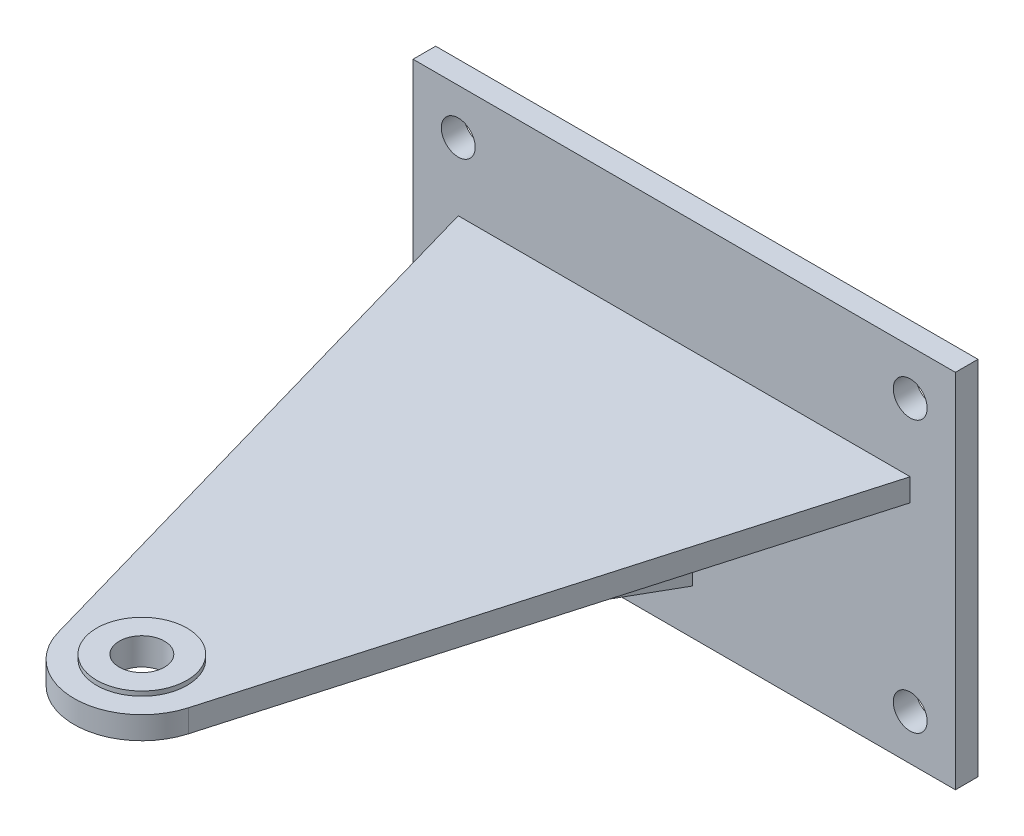
from build123d import *

# Parameters (mm, degrees)
SKETCH1_W            = 152.4
SKETCH1_H            = 101.6
BOSS_EXTRUDE1_DEPTH  = 6.35
BOSS_EXTRUDE2_DEPTH  = 6.35
SKETCH5_R            = 12.7
BOSS_EXTRUDE3_DEPTH  = 1.27
BOSS_EXTRUDE4_DEPTH  = 2.38125
RIB1_REACH           = 212.988
SKETCH7_WALL_W       = 480.772618864
SKETCH7_WALL_H       = 2.54
SKETCH8_R            = 6.35
CUT_EXTRUDE1_DEPTH   = 207.100301795
SKETCH9_R            = 4.7625
CUT_EXTRUDE2_DEPTH   = 195.376393886
LPATTERN1_COUNT      = 2
LPATTERN1_PITCH      = 127
LPATTERN1_COUNT_DIR2 = 2
LPATTERN1_PITCH_DIR2 = 76.2


with BuildPart() as part:
    # Sketch1 → Boss-Extrude1 (new body)
    with BuildSketch(Plane.XY):
        Rectangle(SKETCH1_W, SKETCH1_H)
    extrude(amount=BOSS_EXTRUDE1_DEPTH)

    # Sketch4 → Boss-Extrude2 (add)
    with BuildSketch(Plane(origin=(0, 19.05, 0), x_dir=(1, 0, 0), z_dir=(0, 1, 0))):
        with BuildLine():
            Line((63.5, -6.35), (18.312580006, -163.998991669))
            ThreePointArc((18.312580006, -163.998991669), (0, -177.8), (-18.312580006, -163.998991669))
            Line((-18.312580006, -163.998991669), (-63.5, -6.35))
            Line((-63.5, -6.35), (63.5, -6.35))
        make_face()
    extrude(amount=-BOSS_EXTRUDE2_DEPTH)

    # Sketch5 → Boss-Extrude3 (add)
    with BuildSketch(Plane(origin=(0, 19.05, 0), x_dir=(1, 0, 0), z_dir=(0, 1, 0))):
        with Locations((0, -158.75)):
            Circle(SKETCH5_R)
    extrude(amount=BOSS_EXTRUDE3_DEPTH)

    # Sketch6 → Boss-Extrude4 (add, symmetric)
    with BuildSketch(Plane(origin=(0, 0, 0), x_dir=(0, 0, -1), z_dir=(1, 0, 0))):
        Polygon((-6.35, -38.1), (-146.05, 12.7), (-6.35, 12.7), align=None)
    extrude(amount=BOSS_EXTRUDE4_DEPTH, both=True)

    # Sketch7 wall → Rib1 (add, up to next)
    with BuildSketch(Plane(origin=(25.4, 0, 31.75), x_dir=(0, -0.4472135955, -0.894427191), z_dir=(0, 0.894427191, -0.4472135955)), mode=Mode.PRIVATE) as rib1_sk1:
        Rectangle(SKETCH7_WALL_W, SKETCH7_WALL_H)
    rib1_tool1 = extrude(rib1_sk1.sketch, amount=RIB1_REACH, mode=Mode.PRIVATE) - part.part
    rib1 = rib1_tool1.solids().sort_by_distance((25.4, 0, 31.75))[0]
    add(rib1)

    # Mirror1: Rib1 across plane
    add(rib1.mirror(Plane(origin=(0, 0, 0), x_dir=(0, 0, 1), z_dir=(1, 0, 0))))

    # Sketch8 → Cut-Extrude1 (cut, through all)
    with BuildSketch(Plane(origin=(0, 20.32, 0), x_dir=(1, 0, 0), z_dir=(0, 1, 0))):
        with Locations(Location((0, -158.75, 0), (0, 0, 180))):
            Circle(SKETCH8_R)
    extrude(amount=-CUT_EXTRUDE1_DEPTH, mode=Mode.SUBTRACT)

    # Sketch9 → Cut-Extrude2 (cut, symmetric)
    with BuildSketch(Plane.XY.offset(6.35)):
        with Locations((-63.5, 38.1)):
            Circle(SKETCH9_R)
    cut_extrude2 = extrude(amount=CUT_EXTRUDE2_DEPTH, both=True, mode=Mode.SUBTRACT)

    # LPattern1: Cut-Extrude2 2 × 2
    with Locations(*[(i * LPATTERN1_PITCH, -j * LPATTERN1_PITCH_DIR2, 0) for i in range(LPATTERN1_COUNT) for j in range(LPATTERN1_COUNT_DIR2) if (i, j) != (0, 0)]):
        add(cut_extrude2, mode=Mode.SUBTRACT)


solid = part.part
